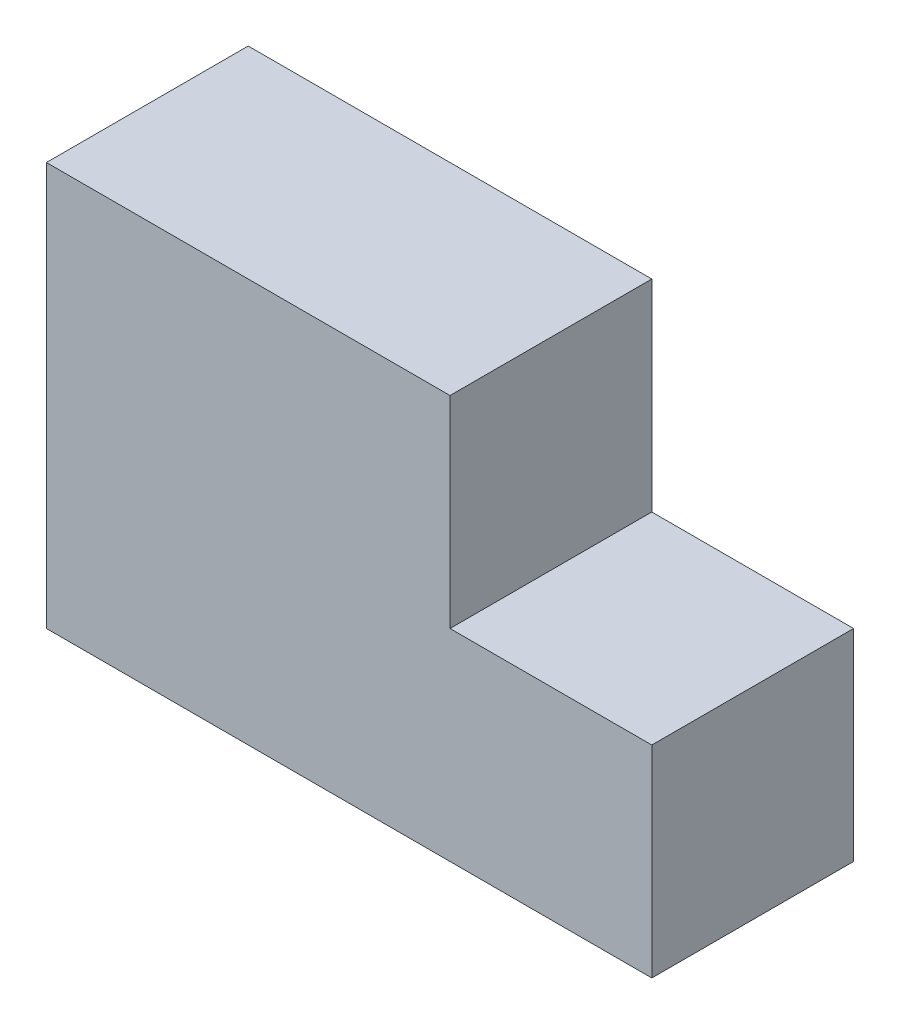
from build123d import *

# Parameters (mm, degrees)
BOSS_EXTRUDE1_DEPTH = 25.4


with BuildPart() as part:
    # Sketch1 → Boss-Extrude1 (new body)
    with BuildSketch(Plane.XY):
        Polygon((0, 50.8), (50.8, 50.8), (50.8, 25.4), (76.2, 25.4), (76.2, 0), (0, 0), align=None)
    extrude(amount=BOSS_EXTRUDE1_DEPTH)


solid = part.part
